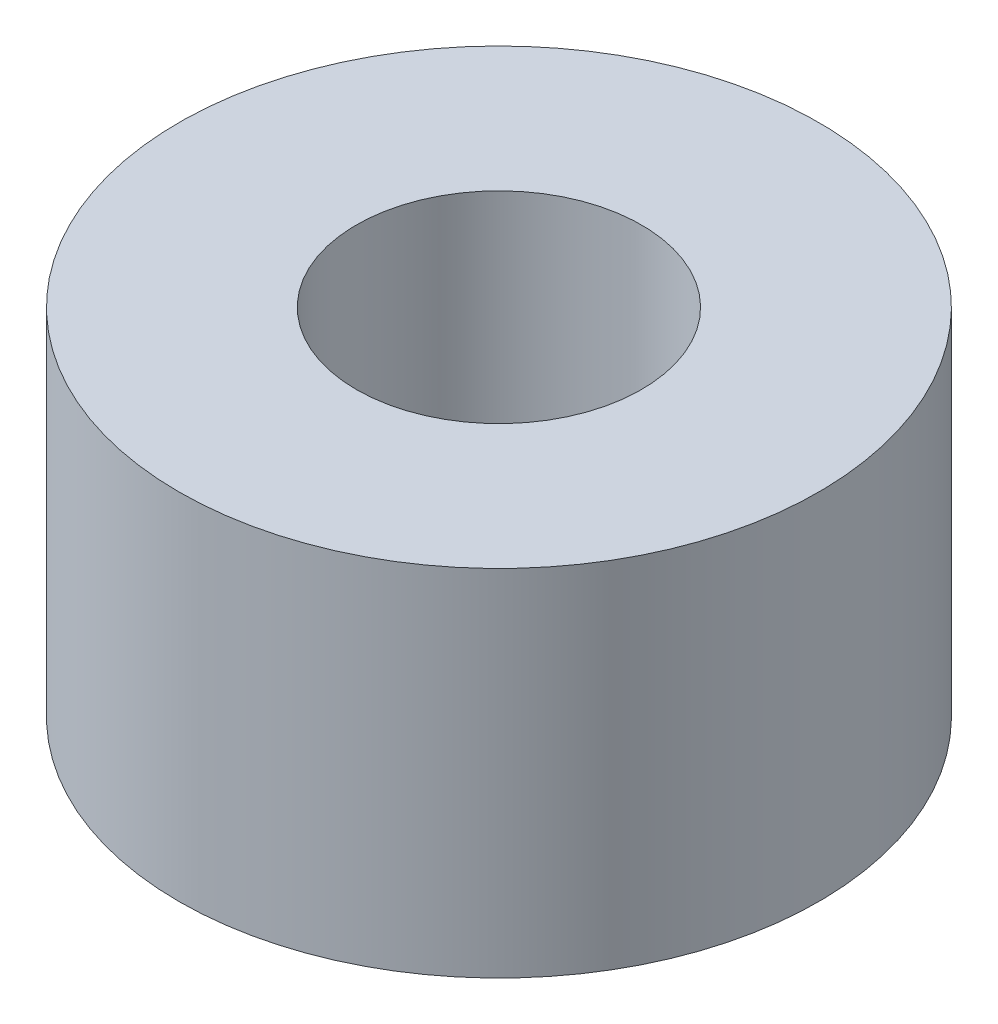
from build123d import *

# Parameters (mm, degrees)
SKETCH1_R           = 5.7277
SKETCH1_R_2         = 2.5527
BOSS_EXTRUDE1_DEPTH = 6.35


with BuildPart() as part:
    # Sketch1 → Boss-Extrude1 (new body)
    with BuildSketch(Plane(origin=(0, 0, 0), x_dir=(1, 0, 0), z_dir=(0, 1, 0))):
        Circle(SKETCH1_R)
        Circle(SKETCH1_R_2, mode=Mode.SUBTRACT)
    extrude(amount=BOSS_EXTRUDE1_DEPTH)


solid = part.part
